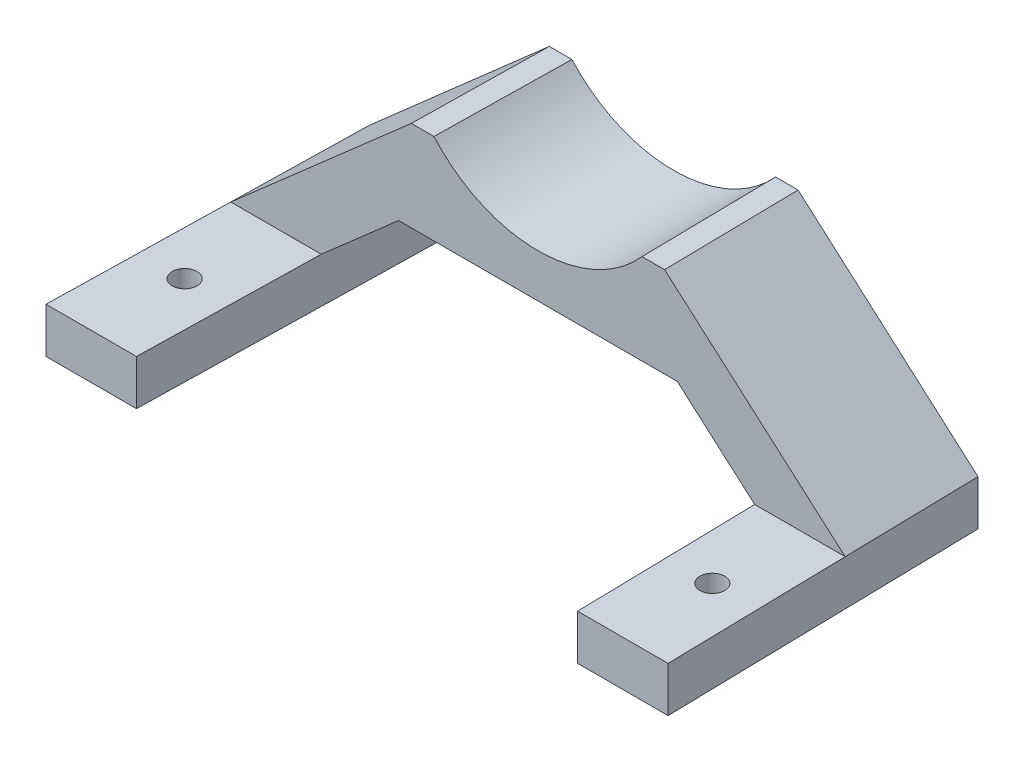
from build123d import *

# Parameters (mm, degrees)
SKETCH1_R             = 2.75
BOSS_EXTRUDE1_DEPTH   = 10
BOSS_EXTRUDE1_2_DEPTH = 10


with BuildPart() as part:
    # Sketch1 → Boss-Extrude1 (new body)
    with BuildSketch(Plane(origin=(0, 0, 0), x_dir=(1, 0, 0), z_dir=(0, 1, 0))):
        Polygon((0, 0), (20.004497681, 0), (21.489122754, 70), (1.484625073, 70), align=None)
        with Locations((10.430924608, 20.212041611)):
            Circle(SKETCH1_R, mode=Mode.SUBTRACT)
    extrude(amount=BOSS_EXTRUDE1_DEPTH)



with BuildPart() as body_2:
    # Sketch1 → Boss-Extrude1 2 (new body)
    with BuildSketch(Plane(origin=(0, 0, 0), x_dir=(1, 0, 0), z_dir=(0, 1, 0))):
        Polygon((116.0383729, 70), (136.042870581, 70), (137.527495654, 0), (117.522997972, 0), align=None)
        with Locations((127.096571045, 20.212041611)):
            Circle(SKETCH1_R, mode=Mode.SUBTRACT)
    extrude(amount=BOSS_EXTRUDE1_2_DEPTH)


with BuildPart() as part_1:
    add(part.part)

    add(body_2.part)  # Loft1 merges body 2
    # Sketch2 → Loft1 section 0
    with BuildSketch(Plane(origin=(0, 0, -70), x_dir=(-1, 0, 0), z_dir=(0, 0, -1))):
        with BuildLine():
            Line((-91.263747827, 45), (-96.263747827, 45))
            Line((-96.263747827, 45), (-136.042870581, 10))
            Line((-136.042870581, 10), (-116.0383729, 10))
            Line((-116.0383729, 10), (-98.990177434, 25))
            Line((-98.990177434, 25), (-38.53731822, 25))
            Line((-38.53731822, 25), (-21.489122754, 10))
            Line((-21.489122754, 10), (-1.484625073, 10))
            Line((-1.484625073, 10), (-41.263747827, 45))
            Line((-41.263747827, 45), (-46.263747827, 45))
            ThreePointArc((-46.263747827, 45), (-68.763747827, 35), (-91.263747827, 45))
        make_face()
    # Sketch3 → Loft1 section 1
    with BuildSketch(Plane(origin=(0, 0, -40), x_dir=(-1, 0, 0), z_dir=(0, 0, -1))):
        with BuildLine():
            Line((-136.679138469, 10), (-96.763747827, 45))
            Line((-96.763747827, 45), (-91.763747827, 45))
            ThreePointArc((-91.763747827, 45), (-68.763747827, 34.627036727), (-45.763747827, 45))
            Line((-45.763747827, 45), (-40.763747827, 45))
            Line((-40.763747827, 45), (-0.848357184, 10))
            Line((-0.848357184, 10), (-20.852854866, 10))
            Line((-20.852854866, 10), (-37.959450855, 25))
            Line((-37.959450855, 25), (-99.568044798, 25))
            Line((-99.568044798, 25), (-116.674640788, 10))
            Line((-116.674640788, 10), (-136.679138469, 10))
        make_face()
    loft()


solid = part_1.part
